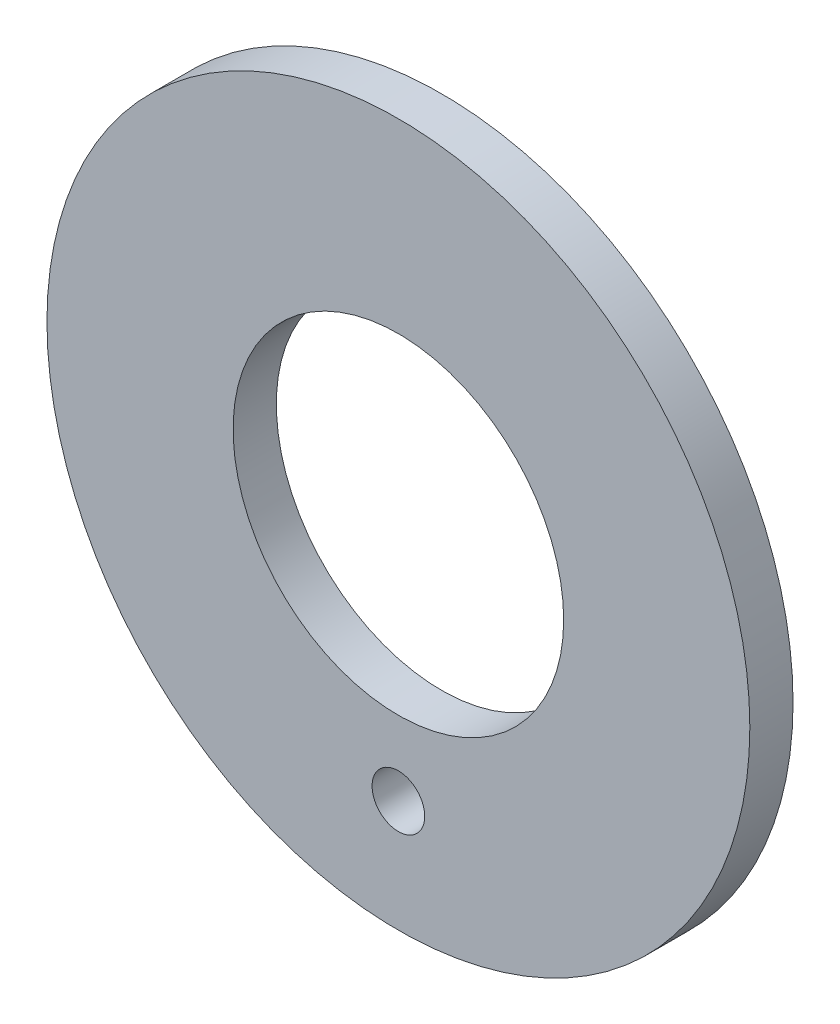
from build123d import *

# Parameters (mm, degrees)
SKETCH1_R           = 11.176
SKETCH1_R_2         = 0.837
SKETCH1_R_3         = 5.2562
BOSS_EXTRUDE1_DEPTH = 1.374


with BuildPart() as part:
    # Sketch1 → Boss-Extrude1 (new body)
    with BuildSketch(Plane.XY):
        Circle(SKETCH1_R)
        with Locations((0, -7.62)):
            Circle(SKETCH1_R_2, mode=Mode.SUBTRACT)
        Circle(SKETCH1_R_3, mode=Mode.SUBTRACT)
    extrude(amount=BOSS_EXTRUDE1_DEPTH)


solid = part.part
